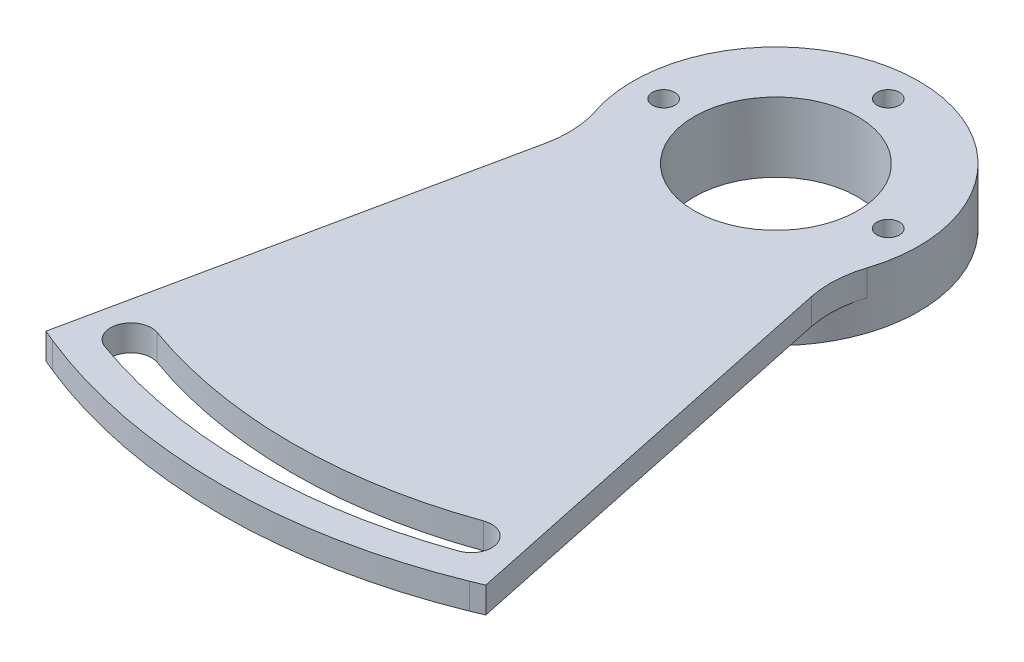
from build123d import *

# Parameters (mm, degrees)
SKETCH1_R           = 1.1
SKETCH1_R_2         = 8
BOSS_EXTRUDE1_DEPTH = 2.54
FILLET2_R           = 10
BOSS_EXTRUDE2_START = -2.999994
SKETCH1_4_R         = 8
SKETCH1_4_R_2       = 1.1
BOSS_EXTRUDE2_DEPTH = 2.999994
BOSS_EXTRUDE3_START = 1.27
SKETCH2_R           = 9
SKETCH2_R_2         = 8
BOSS_EXTRUDE3_DEPTH = 1.27


with BuildPart() as part:
    # Sketch1 → Boss-Extrude1 (new body)
    with BuildSketch(Plane(origin=(0, 0, 0), x_dir=(1, 0, 0), z_dir=(0, 1, 0))):
        with BuildLine():
            Line((20.411129853, -60.145086441), (21.536156884, -59.674942586))
            Line((21.536156884, -59.674942586), (12.379162196, -16.260133485))
            ThreePointArc((12.379162196, -16.260133485), (0, 4.278699998), (-12.379162196, -16.260133485))
            Line((-12.379162196, -16.260133485), (-21.536156884, -59.674942586))
            Line((-21.536156884, -59.674942586), (-20.411129853, -60.145086441))
            ThreePointArc((-20.411129853, -60.145086441), (0, -64.119576268), (20.411129853, -60.145086441))
        make_face()
        with BuildLine():
            ThreePointArc((-17.340734757, -58.10602614), (-18.548712659, -55.548529546), (-15.99121608, -54.340551611))
            ThreePointArc((-15.99121608, -54.340551611), (-6.8e-08, -57.119576403), (15.991215951, -54.340551657))
            ThreePointArc((15.991215951, -54.340551657), (18.548712618, -55.548529433), (17.340734853, -58.106026106))
            ThreePointArc((17.340734853, -58.106026106), (5.1e-08, -61.11957629), (-17.340734757, -58.10602614))
        make_face(mode=Mode.SUBTRACT)
        with Locations((-11, -9.721300002)):
            Circle(SKETCH1_R, mode=Mode.SUBTRACT)
        with Locations((0, -9.721300002)):
            Circle(SKETCH1_R_2, mode=Mode.SUBTRACT)
        with Locations((0, 1.278699998)):
            Circle(SKETCH1_R, mode=Mode.SUBTRACT)
        with Locations((11, -9.721300002)):
            Circle(SKETCH1_R, mode=Mode.SUBTRACT)
    extrude(amount=BOSS_EXTRUDE1_DEPTH)

    # Fillet2
    fillet2_edges = [part.edges().sort_by_distance(p)[0] for p in [
        (-12.379162196, 1.27, 16.260133485),
        (12.379162196, 1.27, 16.260133485),
    ]]
    fillet(fillet2_edges, radius=FILLET2_R)

    # Sketch1_4 → Boss-Extrude2 (add)
    with BuildSketch(Plane(origin=(0, 0, 0), x_dir=(1, 0, 0), z_dir=(0, 1, 0)).offset(BOSS_EXTRUDE2_START)):
        with BuildLine():
            ThreePointArc((-12.379162196, -16.260133485), (0, -23.721300002), (12.379162196, -16.260133485))
            ThreePointArc((12.379162196, -16.260133485), (13.588750324, -13.089662308), (14, -9.721300002))
            ThreePointArc((14, -9.721300002), (-3.368362306, 3.867450323), (-12.379162196, -16.260133485))
        make_face()
        with BuildLine():
            ThreePointArc((-9.9, -9.721300002), (-10.307077747, -10.575617712), (-11.22701591, -10.797619553))
            ThreePointArc((-11.22701591, -10.797619553), (-11.692922253, -8.866982291), (-9.9, -9.721300002))
        make_face(mode=Mode.SUBTRACT)
        with Locations((0, -9.721300002)):
            Circle(SKETCH1_4_R, mode=Mode.SUBTRACT)
        with Locations((0, 1.278699998)):
            Circle(SKETCH1_4_R_2, mode=Mode.SUBTRACT)
        with BuildLine():
            ThreePointArc((12.1, -9.721300002), (11.854317711, -10.414222255), (11.22701591, -10.797619553))
            ThreePointArc((11.22701591, -10.797619553), (10.145682289, -9.028377748), (12.1, -9.721300002))
        make_face(mode=Mode.SUBTRACT)
    extrude(amount=BOSS_EXTRUDE2_DEPTH)

    # Sketch2 → Boss-Extrude3 (add)
    with BuildSketch(Plane.XZ.offset(2.999994).offset(BOSS_EXTRUDE3_START)):
        with Locations((0, 9.721300002)):
            Circle(SKETCH2_R)
        with Locations((0, 9.721300002)):
            Circle(SKETCH2_R_2, mode=Mode.SUBTRACT)
    extrude(amount=-BOSS_EXTRUDE3_DEPTH)


solid = part.part
